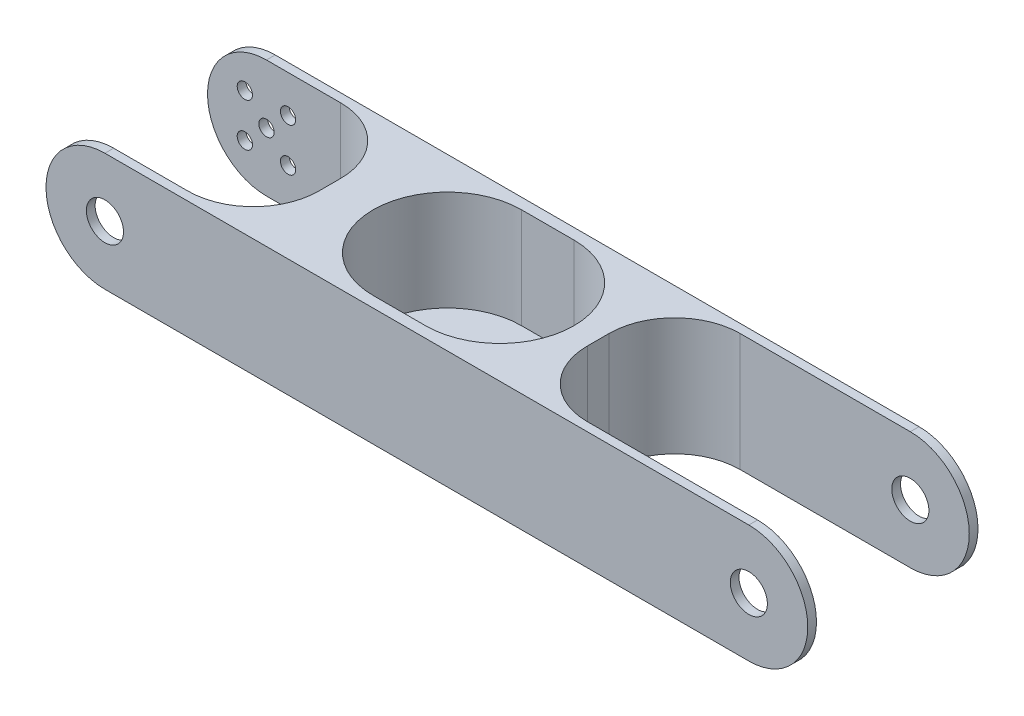
from build123d import *

# Parameters (mm, degrees)
EXTRUDE_1_DEPTH      = 39
SKETCH_2_OUTSIDE_W   = 212.666
SKETCH_2_OUTSIDE_H   = 65.166
SKETCH_2_OUTSIDE_R   = 4.25
CUT_EXTRUDE_2_DEPTH  = 40
CUT_EXTRUDE_4_DEPTH  = 28
CUT_EXTRUDE_7_DEPTH  = 28
CUT_EXTRUDE_9_DEPTH  = 23
CUT_EXTRUDE_10_DEPTH = 28
SKETCH_17_R          = 1.75
CUT_EXTRUDE_13_DEPTH = 2
CUT_EXTRUDE_16_REACH = 41
SKETCH_21_R          = 4.25


with BuildPart() as part:
    # 草图1 → 凸台-拉伸1 (new body)
    with BuildSketch(Plane.XY):
        with BuildLine():
            Line((0, 13.5), (147.5, 13.5))
            ThreePointArc((147.5, 13.5), (161, 0), (147.5, -13.5))
            Line((147.5, -13.5), (0, -13.5))
            ThreePointArc((0, -13.5), (-13.5, 0), (0, 13.5))
        make_face()
    extrude(amount=EXTRUDE_1_DEPTH)

    # 草图2 outside → 切除-拉伸2 (cut, through all)
    with BuildSketch(Plane.XY.offset(39)):
        with Locations((73.75, 0)):
            Rectangle(SKETCH_2_OUTSIDE_W, SKETCH_2_OUTSIDE_H)
        with BuildLine():
            Line((0, -13.5), (147.5, -13.5))
            ThreePointArc((147.5, -13.5), (161, 0), (147.5, 13.5))
            Line((147.5, 13.5), (0, 13.5))
            ThreePointArc((0, 13.5), (-13.5, 0), (0, -13.5))
        make_face(mode=Mode.SUBTRACT)
        with Locations((147.5, 0)):
            Circle(SKETCH_2_OUTSIDE_R)
    extrude(amount=-CUT_EXTRUDE_2_DEPTH, mode=Mode.SUBTRACT)

    # 草图5 → 切除-拉伸4 (cut, through all)
    with BuildSketch(Plane(origin=(0, 13.5, 0), x_dir=(1, 0, 0), z_dir=(0, 1, 0))):
        with BuildLine():
            Line((-32, -37), (17, -37))
            ThreePointArc((17, -37), (27.606601718, -32.606601718), (32, -22))
            Line((32, -22), (32, -17))
            ThreePointArc((32, -17), (27.606601718, -6.393398282), (17, -2))
            Line((17, -2), (-32, -2))
            Line((-32, -2), (-32, -37))
        make_face()
    extrude(amount=-CUT_EXTRUDE_4_DEPTH, mode=Mode.SUBTRACT)

    # 草图11 → 切除-拉伸7 (cut, through all)
    with BuildSketch(Plane.XZ.offset(13.5)):
        with BuildLine():
            Line((108.5, 37), (201.5, 37))
            Line((201.5, 37), (201.5, 2))
            Line((201.5, 2), (108.5, 2))
            ThreePointArc((108.5, 2), (97.893398282, 6.393398282), (93.5, 17))
            Line((93.5, 17), (93.5, 22))
            ThreePointArc((93.5, 22), (97.893398282, 32.606601718), (108.5, 37))
        make_face()
    extrude(amount=-CUT_EXTRUDE_7_DEPTH, mode=Mode.SUBTRACT)

    # 草图14 → 切除-拉伸9 (cut)
    with BuildSketch(Plane(origin=(0, 13.5, 0), x_dir=(1, 0, 0), z_dir=(0, 1, 0))):
        with BuildLine():
            Line((58.944791853, -2.5), (70.944791853, -2.5))
            ThreePointArc((70.944791853, -2.5), (87.944791853, -19.5), (70.944791853, -36.5))
            Line((70.944791853, -36.5), (58.944791853, -36.5))
            ThreePointArc((58.944791853, -36.5), (41.944791853, -19.5), (58.944791853, -2.5))
        make_face()
    extrude(amount=-CUT_EXTRUDE_9_DEPTH, mode=Mode.SUBTRACT)

    # 草图16 → 切除-拉伸10 (cut, through all)
    with BuildSketch(Plane.XZ.offset(13.5)):
        with BuildLine():
            Line((62, 29), (70, 29))
            ThreePointArc((70, 29), (79.5, 19.5), (70, 10))
            Line((70, 10), (62, 10))
            ThreePointArc((62, 10), (52.5, 19.5), (62, 29))
        make_face()
    extrude(amount=-CUT_EXTRUDE_10_DEPTH, mode=Mode.SUBTRACT)

    # 草图17 → 切除-拉伸13 (cut)
    with BuildSketch(Plane(origin=(0, 0, 0), x_dir=(-1, 0, 0), z_dir=(0, 0, -1))):
        with Locations((-4.949747468, 4.949747468)):
            Circle(SKETCH_17_R)
        with Locations((4.949747468, 4.949747468)):
            Circle(SKETCH_17_R)
        with Locations((-4.949747468, -4.949747468)):
            Circle(SKETCH_17_R)
        with Locations((4.949747468, -4.949747468)):
            Circle(SKETCH_17_R)
        Circle(SKETCH_17_R)
    extrude(amount=-CUT_EXTRUDE_13_DEPTH, mode=Mode.SUBTRACT)

    # 草图21 → 切除-拉伸16 (cut, up to next)
    with BuildSketch(Plane.XY.offset(39), mode=Mode.PRIVATE) as cut_extrude_16_sk1:
        Circle(SKETCH_21_R)
    cut_extrude_16_tool1 = extrude(cut_extrude_16_sk1.sketch, amount=-CUT_EXTRUDE_16_REACH, mode=Mode.PRIVATE) & part.part
    add(cut_extrude_16_tool1.solids().sort_by_distance((0, 0, 39))[0], mode=Mode.SUBTRACT)


solid = part.part
